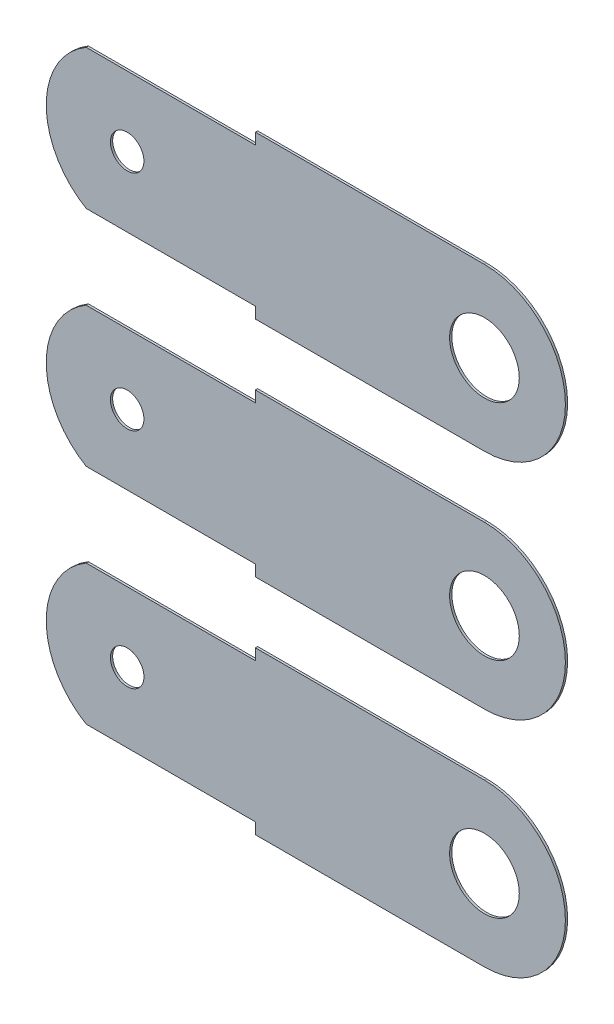
from build123d import *

# Parameters (mm, degrees)
SKETCH1_R           = 0.381
SKETCH1_R_2         = 0.79248
BOSS_EXTRUDE1_DEPTH = 0.0508
SKETCH2_W           = 4.807264271
SKETCH2_H           = 0.712403932
SKETCH2_W_2         = 4.805234364
SKETCH2_H_2         = 0.796216159
CUT_EXTRUDE1_DEPTH  = 0.0508
LPATTERN1_COUNT     = 3
LPATTERN1_PITCH     = 5.08


with BuildPart() as part:
    # Sketch1 → Boss-Extrude1 (new body)
    with BuildSketch(Plane.XY):
        with BuildLine():
            Line((-9.906, 3.2385), (-18.034, 3.2385))
            ThreePointArc((-18.034, 3.2385), (-19.8755, 5.08), (-18.034, 6.9215))
            Line((-18.034, 6.9215), (-9.906, 6.9215))
            ThreePointArc((-9.906, 6.9215), (-8.0645, 5.08), (-9.906, 3.2385))
        make_face()
        with Locations((-18.034, 5.08)):
            Circle(SKETCH1_R, mode=Mode.SUBTRACT)
        with Locations((-9.906, 5.08)):
            Circle(SKETCH1_R_2, mode=Mode.SUBTRACT)
    extrude(amount=BOSS_EXTRUDE1_DEPTH)

    # Sketch2 → Cut-Extrude1 (cut)
    with BuildSketch(Plane.XY.offset(0.0508)):
        with Locations((-17.521048287, 7.023701966)):
            Rectangle(SKETCH2_W, SKETCH2_H)
        with Locations((-17.52206324, 3.094391921)):
            Rectangle(SKETCH2_W_2, SKETCH2_H_2)
    extrude(amount=-CUT_EXTRUDE1_DEPTH, mode=Mode.SUBTRACT)


with BuildPart() as lpattern1_1:
    # LPattern1: pattern copy
    add(part.part.moved(Location(Vector(0, -1, 0) * (1 * LPATTERN1_PITCH))))


with BuildPart() as lpattern1_2:
    # LPattern1: pattern copy
    add(part.part.moved(Location(Vector(0, -1, 0) * (2 * LPATTERN1_PITCH))))


solid = Compound([part.part, lpattern1_1.part, lpattern1_2.part])
